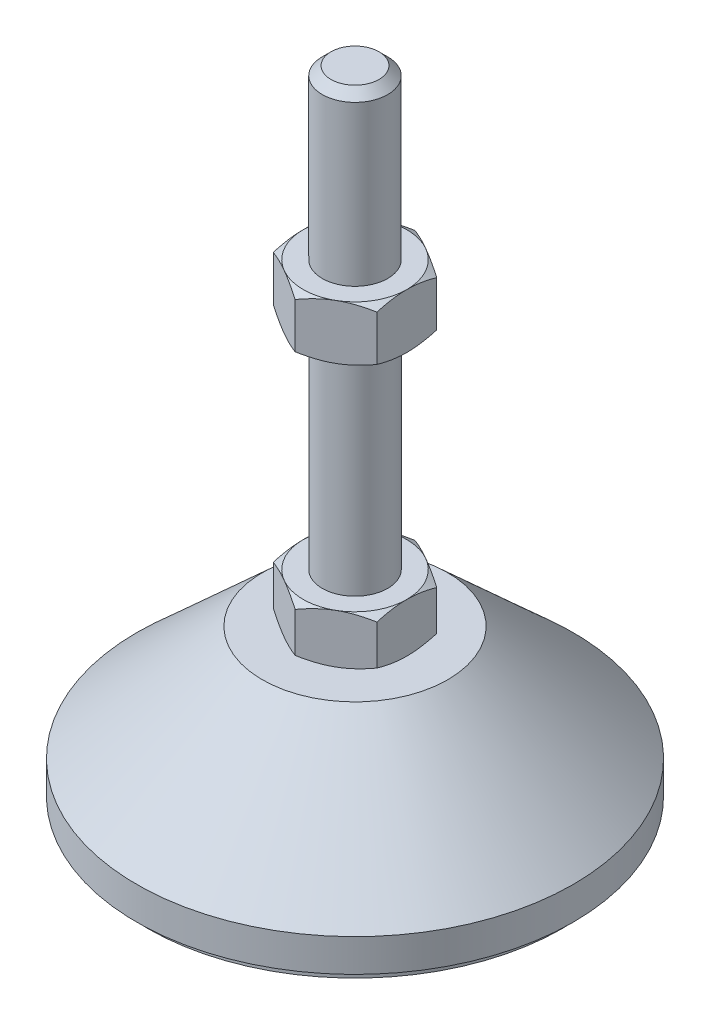
from build123d import *

# Parameters (mm, degrees)
EXTRUDE_1_DEPTH = 9
EXTRUDE_2_DEPTH = 10


with BuildPart() as part:
    # Эскиз1 → Повернуть1 (revolve)
    with BuildSketch(Plane.XY, mode=Mode.PRIVATE) as revolve_1_sk:
        Polygon((0, 0), (-38, 0), (-38, 2), (-40, 2), (-40, 8), (-17, 29), (-6, 29), (-6, 38), (-6, 116.4), (-4.4, 118), (0, 118), align=None)
    revolve(revolve_1_sk.sketch.rotate(Axis((0, 0, 0), (0, 1, 0)), 180), axis=Axis((0, 0, 0), (0, 1, 0)))  # turned: the seam where the file's is

    # Эскиз2 → Бобышка-Вытянуть1 (add)
    with BuildSketch(Plane(origin=(0, 29, 0), x_dir=(1, 0, 0), z_dir=(0, 1, 0))):
        Polygon((0, 10.969655115), (-9.5, 5.484827557), (-9.5, -5.484827557), (0, -10.969655115), (9.5, -5.484827557), (9.5, 5.484827557), align=None)
    extrude(amount=EXTRUDE_1_DEPTH)

    # Эскиз3 → Бобышка-Вытянуть2 (add)
    with BuildSketch(Plane(origin=(0, 77.2, 0), x_dir=(1, 0, 0), z_dir=(0, 1, 0))):
        Polygon((9.5, 5.484827557), (0, 10.969655115), (-9.5, 5.484827557), (-9.5, -5.484827557), (0, -10.969655115), (9.5, -5.484827557), align=None)
    extrude(amount=EXTRUDE_2_DEPTH)

    # Эскиз4 → Вырез-Повернуть2 (revolve, cut)
    with BuildSketch(Plane.XY, mode=Mode.PRIVATE) as cut_revolve_2_sk:
        Polygon((-18.160254038, 87.2), (-9.5, 87.2), (-18.160254038, 82.2), align=None)
        Polygon((-18.160254038, 77.2), (-18.160254038, 82.2), (-9.5, 77.2), align=None)
        Polygon((-17.294228634, 38), (-17.294228634, 33.5), (-9.5, 38), align=None)
        Polygon((-17.294228634, 33.5), (-17.294228634, 29), (-9.5, 29), align=None)
    revolve(cut_revolve_2_sk.sketch.rotate(Axis((0, 118, 0), (0, -1, 0)), 180), axis=Axis((0, 118, 0), (0, -1, 0)), mode=Mode.SUBTRACT)  # turned: the seam where the file's is


solid = part.part
